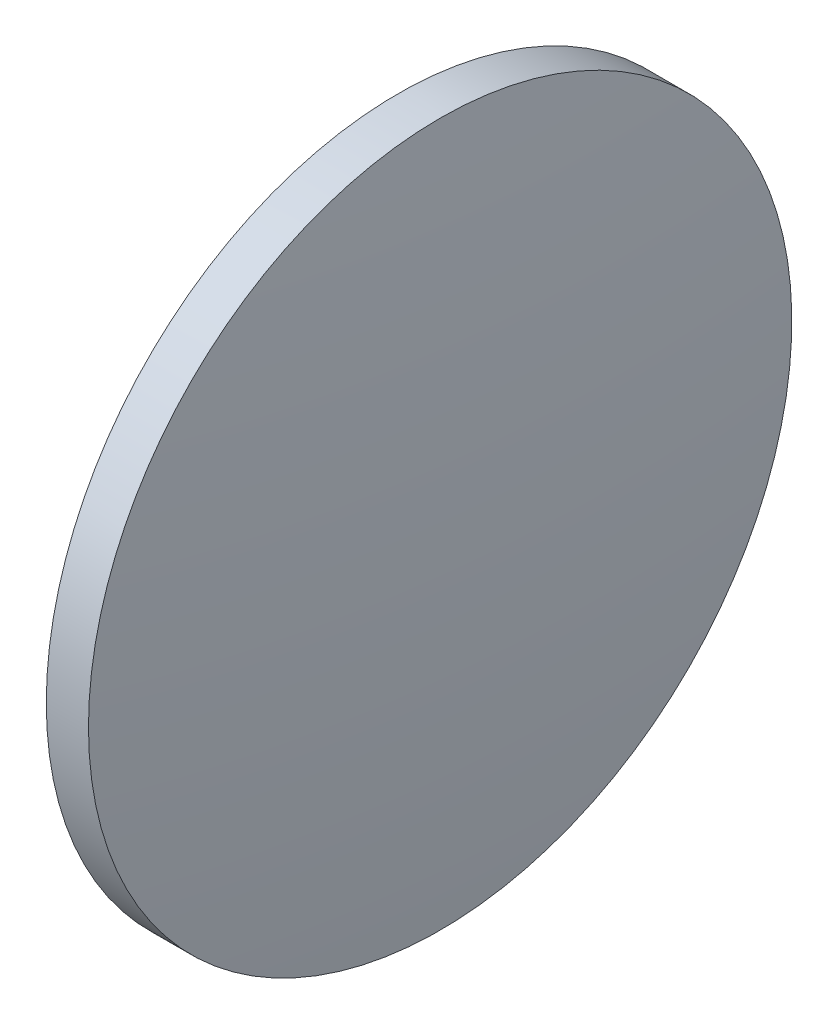
from build123d import *


with BuildPart() as part:
    # 草图1 → 旋转1 (revolve)
    with BuildSketch(Plane.XY):
        with BuildLine():
            Line((462.004636282, 88.871318013), (462.004636282, 113.871318013))
            Line((462.004636282, 113.871318013), (465.004636282, 113.871318013))
            ThreePointArc((465.004636282, 113.871318013), (465.911959333, 101.385950449), (466.214636282, 88.871318013))
            Line((466.214636282, 88.871318013), (462.004636282, 88.871318013))
        make_face()
    revolve(axis=Axis((457.859624533, 88.871318013, 0), (1, 0, 0)))


solid = part.part
